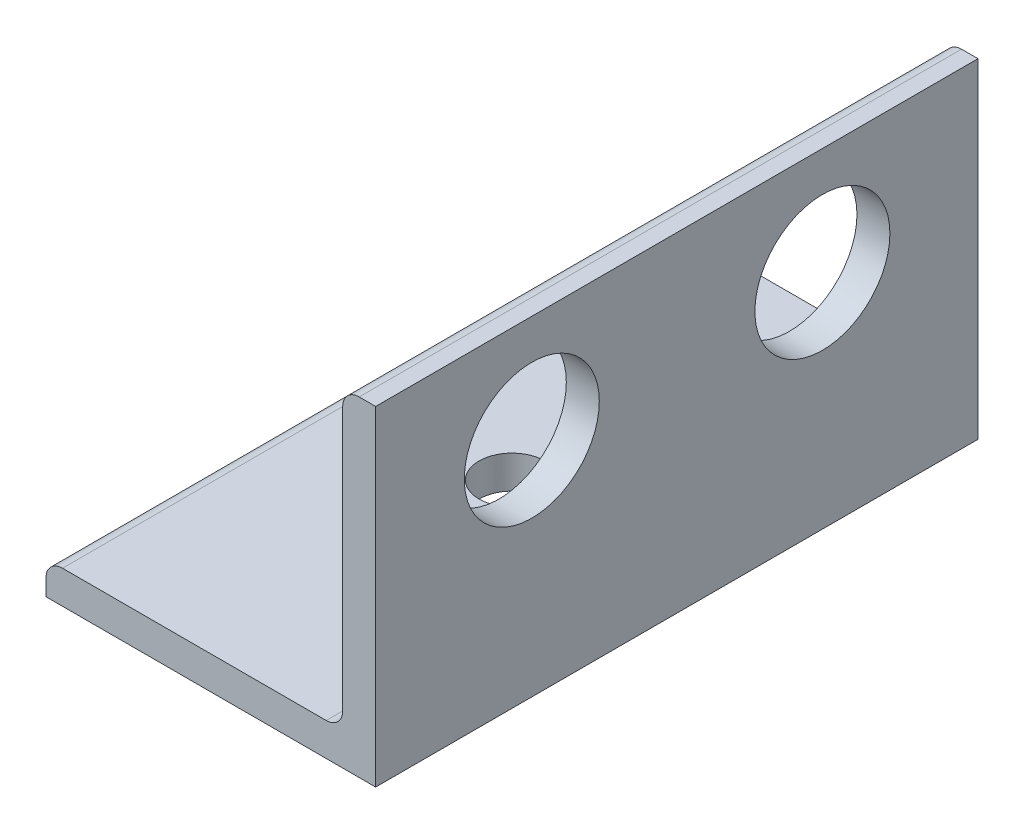
from build123d import *

# Parameters (mm, degrees)
BOSS_EXTRUDE1_DEPTH = 152.4
CUT_EXTRUDE1_REACH  = 17.875
SKETCH3_R           = 3.2512
CUT_EXTRUDE2_START  = -275.7932
CUT_EXTRUDE2_DEPTH  = 275.7932
CUT_EXTRUDE3_REACH  = 17.875
SKETCH5_R           = 1.5875


with BuildPart() as part:
    # Sketch2 → Boss-Extrude1 (new body, symmetric)
    with BuildSketch(Plane.XY):
        with BuildLine():
            Line((-7.9375, 0), (7.9375, 0))
            Line((7.9375, 0), (7.9375, 15.875))
            Line((7.9375, 15.875), (7.14375, 15.875))
            ThreePointArc((7.14375, 15.875), (6.582483992, 15.642516008), (6.35, 15.08125))
            Line((6.35, 15.08125), (6.35, 2.38125))
            ThreePointArc((6.35, 2.38125), (6.117516008, 1.819983992), (5.55625, 1.5875))
            Line((5.55625, 1.5875), (-7.14375, 1.5875))
            ThreePointArc((-7.14375, 1.5875), (-7.705016008, 1.355016008), (-7.9375, 0.79375))
            Line((-7.9375, 0.79375), (-7.9375, 0))
        make_face()
    extrude(amount=BOSS_EXTRUDE1_DEPTH, both=True)

    # Sketch3 → Cut-Extrude1 (cut, up to next)
    with BuildSketch(Plane(origin=(7.9375, 0, 0), x_dir=(0, 0, -1), z_dir=(1, 0, 0)), mode=Mode.PRIVATE) as cut_extrude1_sk1:
        with Locations((144.907, 10.7061)):
            Circle(SKETCH3_R)
    cut_extrude1_tool1 = extrude(cut_extrude1_sk1.sketch, amount=-CUT_EXTRUDE1_REACH, mode=Mode.PRIVATE) & part.part
    add(cut_extrude1_tool1.solids().sort_by_distance((7.9375, 10.7061, -144.907))[0], mode=Mode.SUBTRACT)
    # Sketch3 → Cut-Extrude1 (cut, up to next)
    with BuildSketch(Plane(origin=(7.9375, 0, 0), x_dir=(0, 0, -1), z_dir=(1, 0, 0)), mode=Mode.PRIVATE) as cut_extrude1_sk2:
        with Locations((130.9116, 10.7061)):
            Circle(SKETCH3_R)
    cut_extrude1_tool2 = extrude(cut_extrude1_sk2.sketch, amount=-CUT_EXTRUDE1_REACH, mode=Mode.PRIVATE) & part.part
    add(cut_extrude1_tool2.solids().sort_by_distance((7.9375, 10.7061, -130.9116))[0], mode=Mode.SUBTRACT)

    # Sketch4 → Cut-Extrude2 (cut)
    with BuildSketch(Plane.XY.offset(152.4).offset(CUT_EXTRUDE2_START)):
        with BuildLine():
            Line((-7.9375, 0.79375), (-7.9375, 0))
            Line((-7.9375, 0), (7.9375, 0))
            Line((7.9375, 0), (7.9375, 15.875))
            Line((7.9375, 15.875), (7.14375, 15.875))
            ThreePointArc((7.14375, 15.875), (6.582483992, 15.642516008), (6.35, 15.08125))
            Line((6.35, 15.08125), (6.35, 2.38125))
            ThreePointArc((6.35, 2.38125), (6.117516008, 1.819983992), (5.55625, 1.5875))
            Line((5.55625, 1.5875), (-7.14375, 1.5875))
            ThreePointArc((-7.14375, 1.5875), (-7.705016008, 1.355016008), (-7.9375, 0.79375))
        make_face()
    extrude(amount=CUT_EXTRUDE2_DEPTH, mode=Mode.SUBTRACT)

    # Sketch5 → Cut-Extrude3 (cut, up to next)
    with BuildSketch(Plane.XZ, mode=Mode.PRIVATE) as cut_extrude3_sk1:
        with Locations((0, -137.8966)):
            Circle(SKETCH5_R)
    cut_extrude3_tool1 = extrude(cut_extrude3_sk1.sketch, amount=-CUT_EXTRUDE3_REACH, mode=Mode.PRIVATE) & part.part
    add(cut_extrude3_tool1.solids().sort_by_distance((0, 0, -137.8966))[0], mode=Mode.SUBTRACT)


solid = part.part
